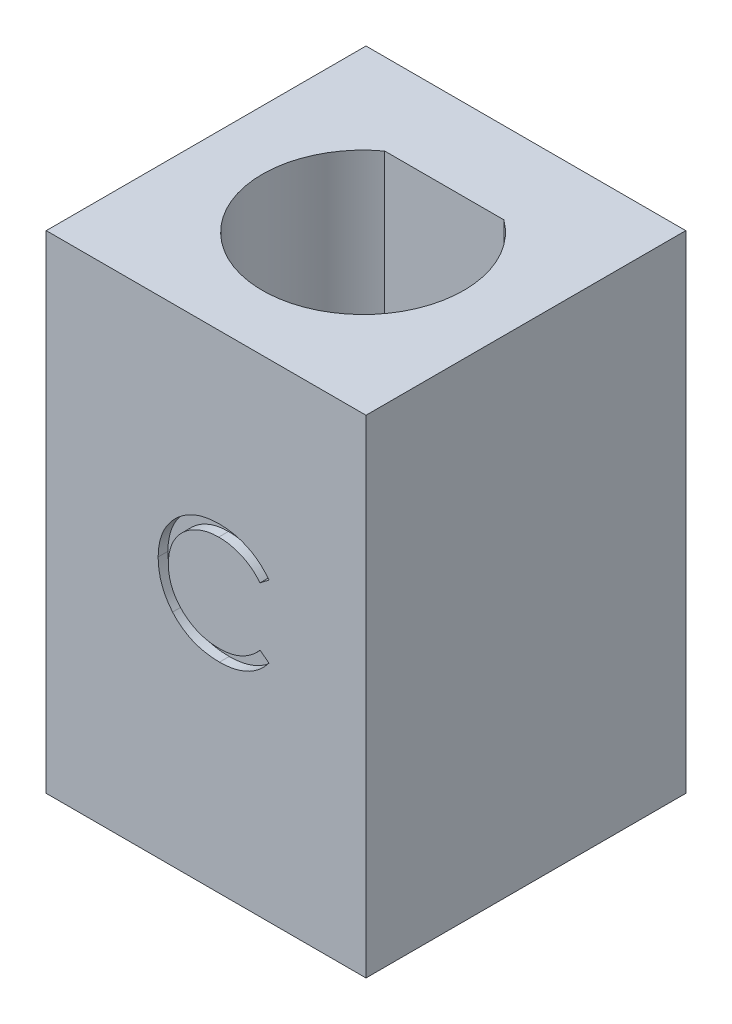
from build123d import *

# Parameters (mm, degrees)
SKETCH1_W           = 9.84142284
SKETCH1_H           = 9.84142284
BOSS_EXTRUDE1_DEPTH = 15
CUT_EXTRUDE1_DEPTH  = 0.3


with BuildPart() as part:
    # Sketch1 → Boss-Extrude1 (new body)
    with BuildSketch(Plane(origin=(0, 0, 0), x_dir=(1, 0, 0), z_dir=(0, 1, 0))):
        Rectangle(SKETCH1_W, SKETCH1_H)
        with BuildLine():
            Line((-1.833030278, 2.409444822), (1.833030278, 2.409444822))
            ThreePointArc((1.833030278, 2.409444822), (0, -3.190555178), (-1.833030278, 2.409444822))
        make_face(mode=Mode.SUBTRACT)
    extrude(amount=BOSS_EXTRUDE1_DEPTH)

    # Sketch2 → Cut-Extrude1 (cut)
    with BuildSketch(Plane.XY.offset(4.92071142)):
        with BuildLine():
            Line((1.934406803, 9.11261109), (1.659567059, 8.902274552))
            add(Edge.make_bspline(
                [(1.659567059, 8.902274552), (1.639961171, 8.925640522), (1.601013724, 8.972057437), (1.538354521, 9.037236982), (1.473052878, 9.098302243), (1.405133757, 9.155544123), (1.333374638, 9.206960889), (1.259513839, 9.255231992), (1.182315794, 9.29849973), (1.075564059, 9.350962716), (0.935916211, 9.405708871), (0.760121372, 9.451612102), (0.576610273, 9.480833278), (0.451412674, 9.483998119), (0.387732123, 9.485607885)],
                knots=[0, 0, 0, 0, 9.1485e-05, 0.000181737, 0.000271024, 0.000359627, 0.000447979, 0.000535687, 0.000624217, 0.000713268, 0.000892422, 0.00107303, 0.001257466, 0.001448389, 0.001448389, 0.001448389, 0.001448389], degree=3))
            add(Edge.make_bspline(
                [(0.387732123, 9.485607885), (0.352648824, 9.485203923), (0.282807831, 9.484399747), (0.179159358, 9.473790622), (0.077446307, 9.458879412), (-0.02226516, 9.436754088), (-0.119848118, 9.408781469), (-0.21594052, 9.375356055), (-0.30915112, 9.334001215), (-0.400769358, 9.288292956), (-0.488548569, 9.236665511), (-0.571603617, 9.180352159), (-0.649631585, 9.119983062), (-0.722694197, 9.055331956), (-0.790866145, 8.986689996), (-0.853653456, 8.913325654), (-0.910838867, 8.83547348), (-0.963555892, 8.754160073), (-1.010768625, 8.669622281), (-1.050298504, 8.581547211), (-1.085303627, 8.491443108), (-1.113002869, 8.398291947), (-1.134927386, 8.302749181), (-1.150055049, 8.204558393), (-1.160543521, 8.103924714), (-1.161343697, 8.035715401), (-1.161747044, 8.001333045)],
                knots=[0, 0, 0, 0, 0.000105206, 0.000209435, 0.000312261, 0.00041348, 0.000515565, 0.000616682, 0.000718413, 0.000821258, 0.000923708, 0.001023662, 0.001122111, 0.001219464, 0.00131614, 0.001412112, 0.001508869, 0.001605718, 0.001702691, 0.001799013, 0.001895107, 0.001992482, 0.002090281, 0.00218895, 0.002290387, 0.00239349, 0.00239349, 0.00239349, 0.00239349], degree=3))
            add(Edge.make_bspline(
                [(-1.161747044, 8.001333045), (-1.160485225, 7.949601726), (-1.15800781, 7.848034141), (-1.135959476, 7.69926353), (-1.102454385, 7.556742856), (-1.052238808, 7.421363014), (-0.990319757, 7.291454656), (-0.912079146, 7.169215803), (-0.821462609, 7.052799238), (-0.717188189, 6.94495629), (-0.602782373, 6.846442565), (-0.480034462, 6.759691983), (-0.349250174, 6.687377101), (-0.211873544, 6.627201155), (-0.06684743, 6.580944427), (0.085567373, 6.548380303), (0.245039368, 6.527138123), (0.354008768, 6.525104435), (0.409466899, 6.524069424)],
                knots=[0, 0, 0, 0, 0.000155106, 0.000304531, 0.000450265, 0.000593548, 0.000736853, 0.000881182, 0.001028026, 0.001178769, 0.001330408, 0.001480379, 0.001628835, 0.001777978, 0.001929641, 0.002084627, 0.002245075, 0.00241136, 0.00241136, 0.00241136, 0.00241136], degree=3))
            add(Edge.make_bspline(
                [(0.409466899, 6.524069424), (0.470569588, 6.525758203), (0.590834297, 6.529082126), (0.767202323, 6.557241375), (0.936038089, 6.602899293), (1.097350675, 6.666797215), (1.250685321, 6.749862503), (1.396281982, 6.850560381), (1.534263552, 6.969848713), (1.617234834, 7.060931842), (1.659567059, 7.107402757)],
                knots=[0, 0, 0, 0, 0.00018322, 0.00036062, 0.000534275, 0.000707044, 0.000879893, 0.001056289, 0.001237208, 0.001425665, 0.001425665, 0.001425665, 0.001425665], degree=3))
            Line((1.659567059, 7.107402757), (1.934406803, 6.899169584))
            add(Edge.make_bspline(
                [(1.934406803, 6.899169584), (1.912288693, 6.870631132), (1.868158417, 6.813690926), (1.7967004, 6.733419216), (1.721423103, 6.65791518), (1.641767393, 6.587787559), (1.558649601, 6.521633094), (1.470577289, 6.461331262), (1.378708257, 6.406040378), (1.283353778, 6.355413454), (1.184615165, 6.310496207), (1.08261073, 6.272042439), (0.977780154, 6.238917549), (0.870118646, 6.211665612), (0.759402889, 6.190394529), (0.646032415, 6.176174854), (0.52976254, 6.166432939), (0.451321119, 6.165545024), (0.411570264, 6.165095065)],
                knots=[0, 0, 0, 0, 0.000108293, 0.000216068, 0.000322162, 0.000427957, 0.000534281, 0.00064066, 0.000747915, 0.000855806, 0.000964371, 0.001073102, 0.001182643, 0.001294024, 0.001406092, 0.001520624, 0.001636667, 0.001755891, 0.001755891, 0.001755891, 0.001755891], degree=3))
            add(Edge.make_bspline(
                [(0.411570264, 6.165095065), (0.373926597, 6.165357057), (0.299490907, 6.165875115), (0.189592155, 6.174267282), (0.082602575, 6.185717019), (-0.021172051, 6.20295715), (-0.122298026, 6.22330149), (-0.219858611, 6.250572747), (-0.314813821, 6.281121914), (-0.406782162, 6.3170269), (-0.495841862, 6.357543083), (-0.581705673, 6.403334642), (-0.664334105, 6.454016507), (-0.744539526, 6.508471517), (-0.82113711, 6.568448819), (-0.894790635, 6.633115453), (-0.965913112, 6.702253464), (-1.009915797, 6.752108317), (-1.032039512, 6.777174392)],
                knots=[0, 0, 0, 0, 0.0001129, 0.000223246, 0.000330481, 0.000435603, 0.000538732, 0.000639764, 0.000739316, 0.000837878, 0.000935767, 0.001032686, 0.001129604, 0.00122645, 0.001323362, 0.001421241, 0.001520399, 0.001620667, 0.001620667, 0.001620667, 0.001620667], degree=3))
            add(Edge.make_bspline(
                [(-1.032039512, 6.777174392), (-1.067475155, 6.82071558), (-1.137918632, 6.907272291), (-1.228044315, 7.047558272), (-1.305191871, 7.194026481), (-1.367567791, 7.34744641), (-1.416330525, 7.507473797), (-1.45011172, 7.674189311), (-1.472063324, 7.847437254), (-1.474573613, 7.965274042), (-1.475849608, 8.025171186)],
                knots=[0, 0, 0, 0, 0.000168306, 0.00033458, 0.000499224, 0.000664315, 0.00083066, 0.00100034, 0.001174094, 0.001353718, 0.001353718, 0.001353718, 0.001353718], degree=3))
            add(Edge.make_bspline(
                [(-1.475849608, 8.025171186), (-1.474294414, 8.08812664), (-1.471234668, 8.211987565), (-1.445238872, 8.393761518), (-1.403420076, 8.567912917), (-1.344023188, 8.734116661), (-1.268717836, 8.893246942), (-1.175691223, 9.044088146), (-1.06602408, 9.187604946), (-0.940576513, 9.321619697), (-0.803009177, 9.44415905), (-0.655690363, 9.551965254), (-0.498908416, 9.64168277), (-0.334390565, 9.716678932), (-0.160904883, 9.774323395), (0.021178486, 9.814676582), (0.211517401, 9.839793698), (0.341379826, 9.842968906), (0.407363533, 9.844582244)],
                knots=[0, 0, 0, 0, 0.000188789, 0.000371431, 0.000549644, 0.000725278, 0.00089996, 0.001076844, 0.001255917, 0.001440951, 0.001626689, 0.001807878, 0.001987546, 0.002167657, 0.002349462, 0.002534866, 0.002726448, 0.002924344, 0.002924344, 0.002924344, 0.002924344], degree=3))
            add(Edge.make_bspline(
                [(0.407363533, 9.844582244), (0.447578005, 9.844100106), (0.527178503, 9.843145762), (0.644931155, 9.83383962), (0.759573482, 9.818326014), (0.871184464, 9.797209944), (0.98030708, 9.771002622), (1.086107321, 9.736862324), (1.189206008, 9.697825793), (1.288952916, 9.652867327), (1.384869466, 9.602400585), (1.476925785, 9.546984962), (1.564390643, 9.486689156), (1.647879492, 9.422025981), (1.725995703, 9.351627422), (1.800957181, 9.277429826), (1.87021826, 9.197296001), (1.912971455, 9.140891068), (1.934406803, 9.11261109)],
                knots=[0, 0, 0, 0, 0.000120626, 0.000238766, 0.000354085, 0.000467531, 0.000579423, 0.000690512, 0.000800803, 0.000910007, 0.001018518, 0.001125773, 0.001232152, 0.001337058, 0.001442329, 0.001547432, 0.001653292, 0.001759736, 0.001759736, 0.001759736, 0.001759736], degree=3))
        make_face()
    extrude(amount=-CUT_EXTRUDE1_DEPTH, mode=Mode.SUBTRACT)


solid = part.part
